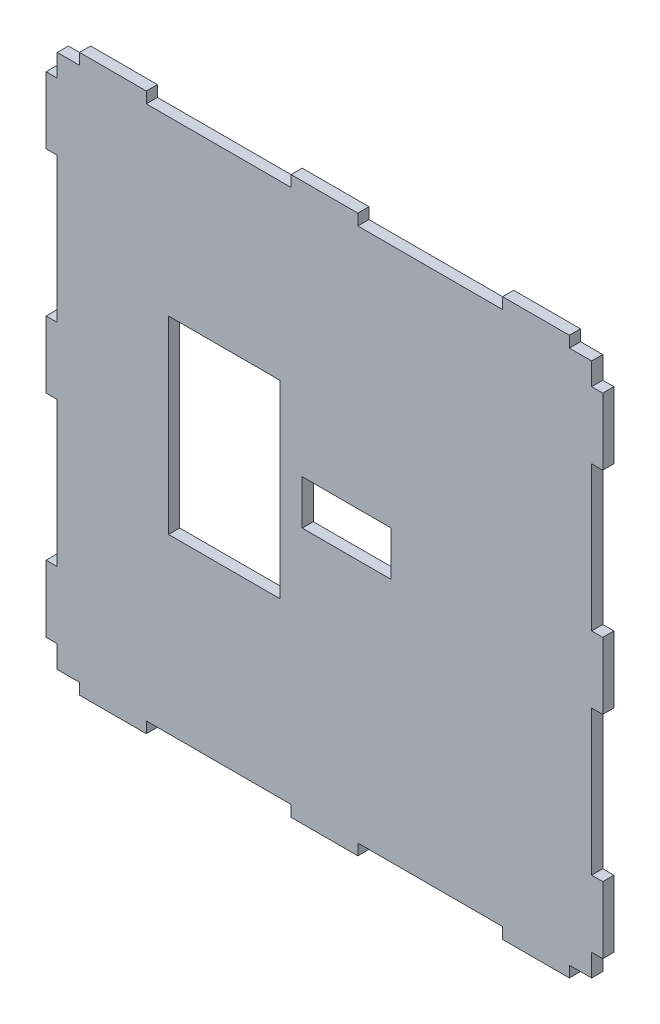
from build123d import *

# Parameters (mm, degrees)
SKETCH5_W           = 50
SKETCH5_H           = 84.944653118
SKETCH5_W_2         = 40
SKETCH5_H_2         = 20
BOSS_EXTRUDE1_DEPTH = 5


with BuildPart() as part:
    # Sketch5 → Boss-Extrude1 (new body)
    with BuildSketch(Plane.XY):
        Polygon((-110, 120), (-120, 120), (-120, 110), (-125, 110), (-125, 80), (-120, 80), (-120, 15), (-125, 15), (-125, -15), (-120, -15), (-120, -80), (-125, -80), (-125, -110), (-120, -110), (-120, -120), (-110, -120), (-110, -125), (-80, -125), (-80, -120), (-15, -120), (-15, -125), (15, -125), (15, -120), (80, -120), (80, -125), (110, -125), (110, -120), (120, -120), (120, -110), (125, -110), (125, -80), (120, -80), (120, -15), (125, -15), (125, 15), (120, 15), (120, 80), (125, 80), (125, 110), (120, 110), (120, 120), (110, 120), (110, 125), (80, 125), (80, 120), (15, 120), (15, 125), (-15, 125), (-15, 120), (-80, 120), (-80, 125), (-110, 125), align=None)
        with Locations((-45, 0)):
            Rectangle(SKETCH5_W, SKETCH5_H, mode=Mode.SUBTRACT)
        with Locations((10, 0)):
            Rectangle(SKETCH5_W_2, SKETCH5_H_2, mode=Mode.SUBTRACT)
    extrude(amount=BOSS_EXTRUDE1_DEPTH)


solid = part.part
